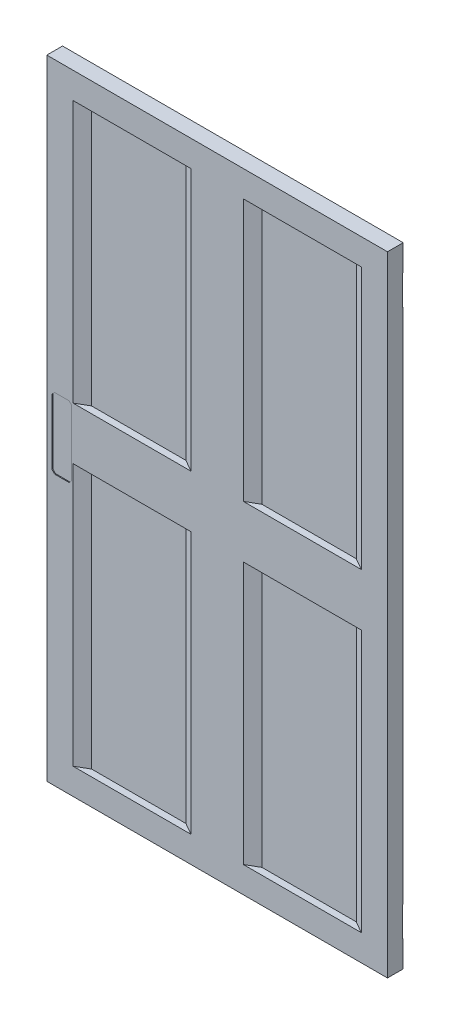
from build123d import *

# Parameters (mm, degrees)
SKETCH1_W                = 1300
SKETCH1_H                = 2400
BOSS_EXTRUDE1_DEPTH      = 60
CUT_EXTRUDE4_DEPTH       = 1100
CUT_EXTRUDE4_DEPTH_BACK  = 1100
BOSS_EXTRUDE2_DEPTH      = 100
BOSS_EXTRUDE2_DEPTH_BACK = 100
SKETCH7_W                = 55.5
SKETCH7_H                = 114
CUT_EXTRUDE5_DEPTH       = 3.4
CUT_EXTRUDE6_DEPTH       = 3.4
SKETCH13_W               = 195
SKETCH13_H               = 40
CUT_EXTRUDE7_DEPTH       = 5


with BuildPart() as part:
    # Sketch1 → Boss-Extrude1 (new body)
    with BuildSketch(Plane.XY):
        with Locations((90.331491713, 213.812154696)):
            Rectangle(SKETCH1_W, SKETCH1_H)
    extrude(amount=BOSS_EXTRUDE1_DEPTH)

    # Sketch5 → Cut-Extrude4 (cut, two sides)
    with BuildSketch(Plane(origin=(0, 213.812154696, 0), x_dir=(-1, 0, 0), z_dir=(0, -1, 0))) as cut_extrude4_sk:
        Polygon((-190.331491713, 0), (-235.364812709, -26), (-595.298170716, -26), (-640.331491713, 0), align=None)
        Polygon((9.668508287, 0), (459.668508287, 0), (414.635187291, -26), (54.701829284, -26), align=None)
        Polygon((414.635187291, -34), (459.668508287, -60), (9.668508287, -60), (54.701829284, -34), align=None)
        Polygon((-190.331491713, -60), (-235.364812709, -34), (-595.298170716, -34), (-640.331491713, -60), align=None)
    extrude(amount=CUT_EXTRUDE4_DEPTH, mode=Mode.SUBTRACT)
    extrude(cut_extrude4_sk.sketch, amount=-CUT_EXTRUDE4_DEPTH_BACK, mode=Mode.SUBTRACT)

    # Sketch6 → Boss-Extrude2 (add, two sides)
    with BuildSketch(Plane(origin=(0, 213.812154696, 0), x_dir=(-1, 0, 0), z_dir=(0, -1, 0))) as boss_extrude2_sk:
        Polygon((-190.331491713, 0), (-235.364812709, -26), (-595.298170716, -26), (-640.331491713, 0), align=None)
        Polygon((9.668508287, 0), (459.668508287, 0), (414.635187291, -26), (54.701829284, -26), align=None)
        Polygon((414.635187291, -34), (459.668508287, -60), (9.668508287, -60), (54.701829284, -34), align=None)
        Polygon((-190.331491713, -60), (-235.364812709, -34), (-595.298170716, -34), (-640.331491713, -60), align=None)
    extrude(amount=BOSS_EXTRUDE2_DEPTH)
    extrude(boss_extrude2_sk.sketch, amount=-BOSS_EXTRUDE2_DEPTH_BACK)

    # Sketch7 → Cut-Extrude5 (cut)
    with BuildSketch(Plane(origin=(0, 0, 0), x_dir=(-1, 0, 0), z_dir=(0, 0, -1))):
        with Locations((-712.581491713, 1256.812154696)):
            Rectangle(SKETCH7_W, SKETCH7_H)
        with Locations((-712.581491713, -829.187845304)):
            Rectangle(SKETCH7_W, SKETCH7_H)
        Polygon((474.668508287, 313.812154696), (529.668508287, 313.812154696), (539.668508287, 303.812154696), (539.668508287, 53.812154696), (529.668508287, 43.812154696), (474.668508287, 43.812154696), (464.668508287, 53.812154696), (464.668508287, 303.812154696), align=None)
    extrude(amount=-CUT_EXTRUDE5_DEPTH, mode=Mode.SUBTRACT)

    # Sketch10 → Cut-Extrude6 (cut)
    with BuildSketch(Plane.XY.offset(60)):
        Polygon((-529.668508287, 313.812154696), (-474.668508287, 313.812154696), (-464.668508287, 303.812154696), (-464.668508287, 53.812154696), (-474.668508287, 43.812154696), (-529.668508287, 43.812154696), (-539.668508287, 53.812154696), (-539.668508287, 303.812154696), align=None)
    extrude(amount=-CUT_EXTRUDE6_DEPTH, mode=Mode.SUBTRACT)

    # Sketch13 → Cut-Extrude7 (cut)
    with BuildSketch(Plane(origin=(0, 0, 0), x_dir=(-1, 0, 0), z_dir=(0, 0, -1))):
        with Locations((-499.186786697, -952.846120584)):
            Rectangle(SKETCH13_W, SKETCH13_H)
    extrude(amount=-CUT_EXTRUDE7_DEPTH, mode=Mode.SUBTRACT)


solid = part.part
